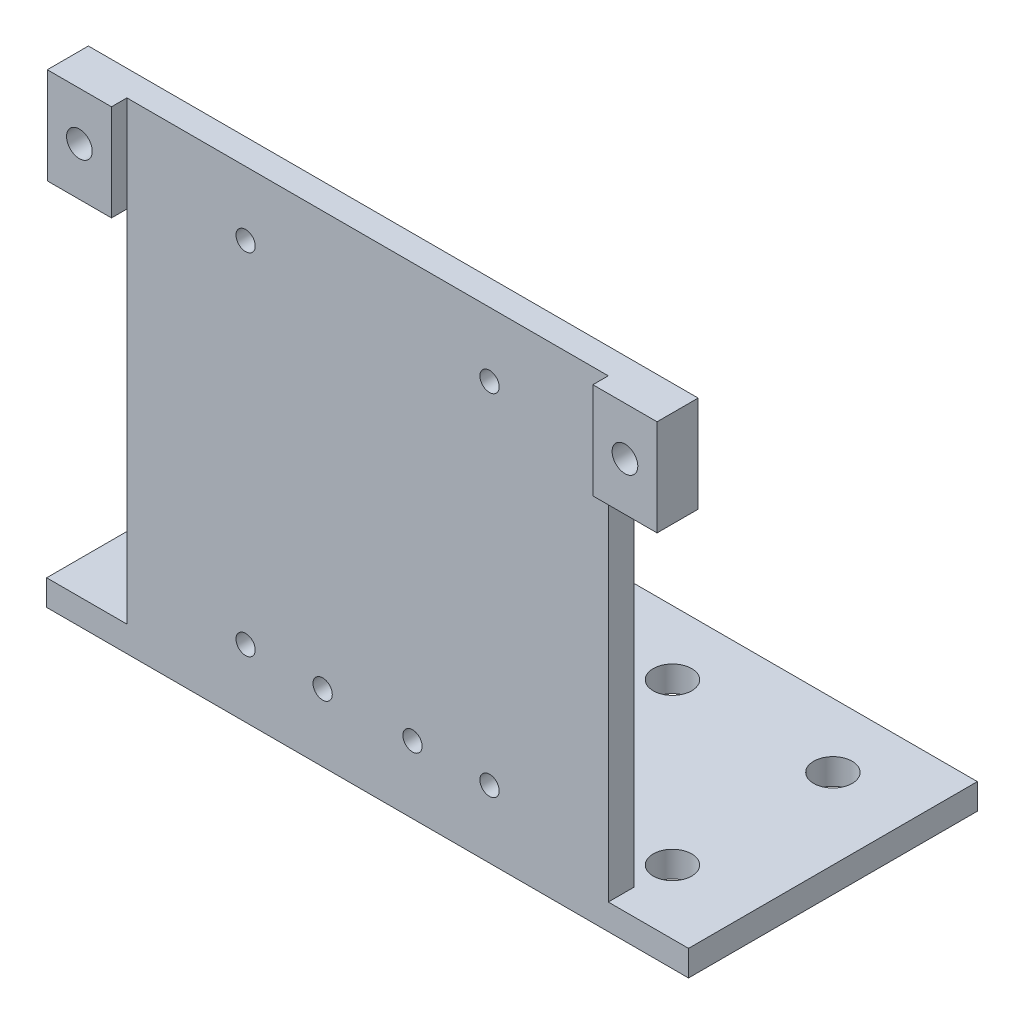
from build123d import *

# Parameters (mm, degrees)
SKETCH_1_W          = 100
SKETCH_1_H          = 45
SKETCH_1_R          = 3
EXTRUDE_1_DEPTH     = 4
SKETCH_2_R          = 1.5
SKETCH_2_R_2        = 2
EXTRUDE_2_DEPTH     = 4
SKETCH_3_W          = 10
SKETCH_3_H          = 15
SKETCH_3_R          = 2
EXTRUDE_3_DEPTH     = 2.4
EXTRUDE_4_DEPTH     = 75
SKETCH_5_R          = 1.5
CUT_EXTRUDE_1_DEPTH = 75
CUT_EXTRUDE_2_DEPTH = 75


with BuildPart() as part:
    # 草图1 → 凸台-拉伸1 (new body)
    with BuildSketch(Plane(origin=(0, 0, 0), x_dir=(1, 0, 0), z_dir=(0, 1, 0))):
        with Locations((50, 22.5)):
            Rectangle(SKETCH_1_W, SKETCH_1_H)
        with Locations((12.5, 35)):
            Circle(SKETCH_1_R, mode=Mode.SUBTRACT)
        with Locations((37.5, 35)):
            Circle(SKETCH_1_R, mode=Mode.SUBTRACT)
        with Locations((37.5, 10)):
            Circle(SKETCH_1_R, mode=Mode.SUBTRACT)
        with Locations((12.5, 10)):
            Circle(SKETCH_1_R, mode=Mode.SUBTRACT)
        with Locations((62.5, 35)):
            Circle(SKETCH_1_R, mode=Mode.SUBTRACT)
        with Locations((62.5, 10)):
            Circle(SKETCH_1_R, mode=Mode.SUBTRACT)
        with Locations((87.5, 10)):
            Circle(SKETCH_1_R, mode=Mode.SUBTRACT)
        with Locations((87.5, 35)):
            Circle(SKETCH_1_R, mode=Mode.SUBTRACT)
    extrude(amount=EXTRUDE_1_DEPTH)

    # 草图2 → 凸台-拉伸2 (add)
    with BuildSketch(Plane.XY):
        Polygon((12.5, 60), (12.5, 0), (87.5, 0), (87.5, 60), (97.5, 60), (97.5, 75), (2.5, 75), (2.5, 60), align=None)
        with Locations((31, 10.5)):
            Circle(SKETCH_2_R, mode=Mode.SUBTRACT)
        with Locations((43, 10.5)):
            Circle(SKETCH_2_R, mode=Mode.SUBTRACT)
        with Locations((57, 10.5)):
            Circle(SKETCH_2_R, mode=Mode.SUBTRACT)
        with Locations((69, 10.5)):
            Circle(SKETCH_2_R, mode=Mode.SUBTRACT)
        with Locations((7.5, 67.5)):
            Circle(SKETCH_2_R_2, mode=Mode.SUBTRACT)
        with Locations((31, 65)):
            Circle(SKETCH_2_R, mode=Mode.SUBTRACT)
        with Locations((69, 65)):
            Circle(SKETCH_2_R, mode=Mode.SUBTRACT)
        with Locations((92.5, 67.5)):
            Circle(SKETCH_2_R_2, mode=Mode.SUBTRACT)
    extrude(amount=-EXTRUDE_2_DEPTH)

    # 草图3 → 凸台-拉伸3 (add)
    with BuildSketch(Plane.XY):
        with Locations((7.5, 67.5)):
            Rectangle(SKETCH_3_W, SKETCH_3_H)
        with Locations((7.5, 67.5)):
            Circle(SKETCH_3_R, mode=Mode.SUBTRACT)
        with Locations((92.5, 67.5)):
            Rectangle(SKETCH_3_W, SKETCH_3_H)
        with Locations((92.5, 67.5)):
            Circle(SKETCH_3_R, mode=Mode.SUBTRACT)
    extrude(amount=EXTRUDE_3_DEPTH)

    # 草图4 → 凸台-拉伸4 (add)
    with BuildSketch(Plane(origin=(87.5, 0, 0), x_dir=(0, 0, -1), z_dir=(1, 0, 0))):
        Polygon((4, 60), (4, 4), (12.5, 4), align=None)
    extrude(amount=-EXTRUDE_4_DEPTH)

    # 草图5 → 切除-拉伸1 (cut)
    with BuildSketch(Plane.XY):
        with Locations((31, 10.5)):
            Circle(SKETCH_5_R)
        with Locations((43, 10.5)):
            Circle(SKETCH_5_R)
        with Locations((57, 10.5)):
            Circle(SKETCH_5_R)
        with Locations((69, 10.5)):
            Circle(SKETCH_5_R)
    extrude(amount=-CUT_EXTRUDE_1_DEPTH, mode=Mode.SUBTRACT)

    # 草图6 → 切除-拉伸2 (cut)
    with BuildSketch(Plane(origin=(0, 4, 0), x_dir=(1, 0, 0), z_dir=(0, 1, 0))):
        Polygon((12.5, 7), (12.5, 4), (21, 4), (21, 12.5), (14.158312395, 12.5), (12.5, 12.5), align=None)
        Polygon((25, 12.5), (25, 4), (75, 4), (75, 12.5), (64.158312395, 12.5), (60.841687605, 12.5), (39.158312395, 12.5), (35.841687605, 12.5), align=None)
        Polygon((79, 12.5), (79, 4), (87.5, 4), (87.5, 7), (87.5, 12.5), (85.841687605, 12.5), align=None)
    extrude(amount=CUT_EXTRUDE_2_DEPTH, mode=Mode.SUBTRACT)


solid = part.part
